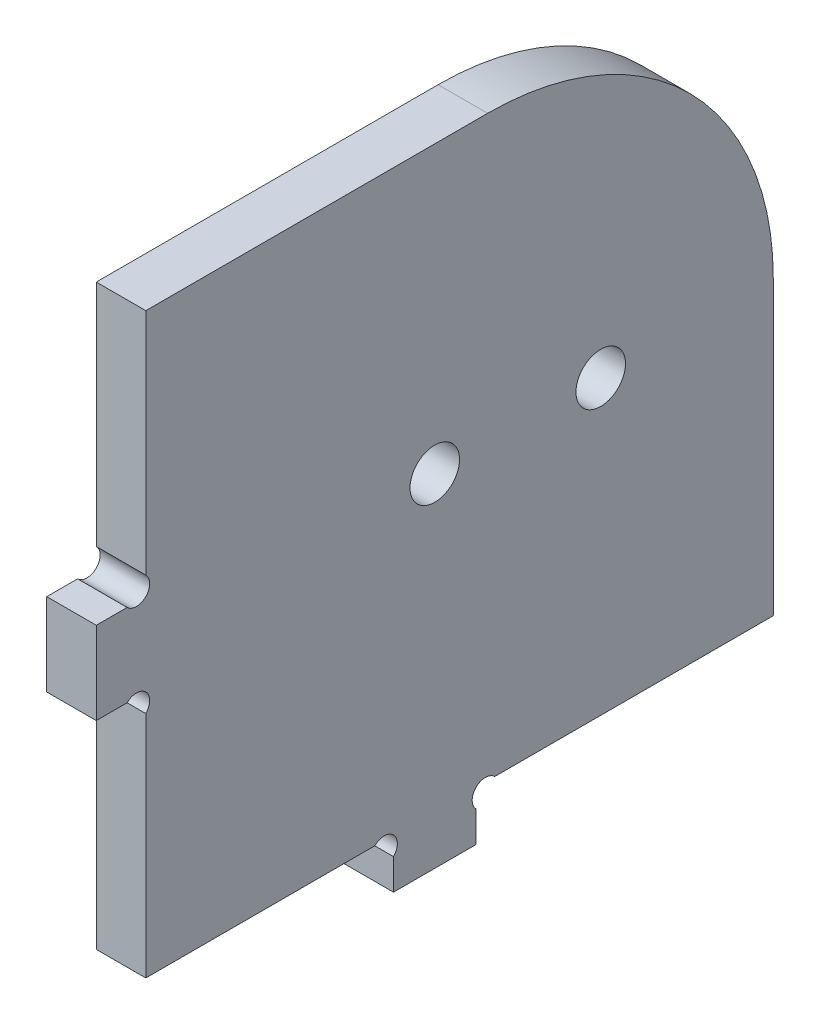
from build123d import *

# Parameters (mm, degrees)
ESQUISSE1_R        = 3
BOSS_EXTRU_1_DEPTH = 6


with BuildPart() as part:
    # Esquisse1 → Boss.-Extru.1 (new body)
    with BuildSketch(Plane(origin=(0, 0, 0), x_dir=(0, 0, -1), z_dir=(1, 0, 0))):
        with BuildLine():
            Line((46, 3.7372583), (46, 0))
            Line((46, 0), (36, 0))
            Line((36, 0), (36, 3.7372583))
            ThreePointArc((36, 3.7372583), (36, 6), (33.7372583, 6))
            Line((33.7372583, 6), (6, 6))
            Line((6, 6), (6, 33.7372583))
            ThreePointArc((6, 33.7372583), (6, 36), (3.7372583, 36))
            Line((3.7372583, 36), (0, 36))
            Line((0, 36), (0, 46))
            Line((0, 46), (3.7372583, 46))
            ThreePointArc((3.7372583, 46), (6, 46), (6, 48.2627417))
            Line((6, 48.2627417), (6, 76))
            Line((6, 76), (47.4, 76))
            ThreePointArc((47.4, 76), (71.865894629, 65.865894629), (82, 41.4))
            Line((82, 41.4), (82, 6))
            Line((82, 6), (48.2627417, 6))
            ThreePointArc((48.2627417, 6), (46, 6), (46, 3.7372583))
        make_face()
        with Locations((41, 41.4)):
            Circle(ESQUISSE1_R, mode=Mode.SUBTRACT)
        with Locations((61.1, 41.4)):
            Circle(ESQUISSE1_R, mode=Mode.SUBTRACT)
    extrude(amount=BOSS_EXTRU_1_DEPTH)


solid = part.part
